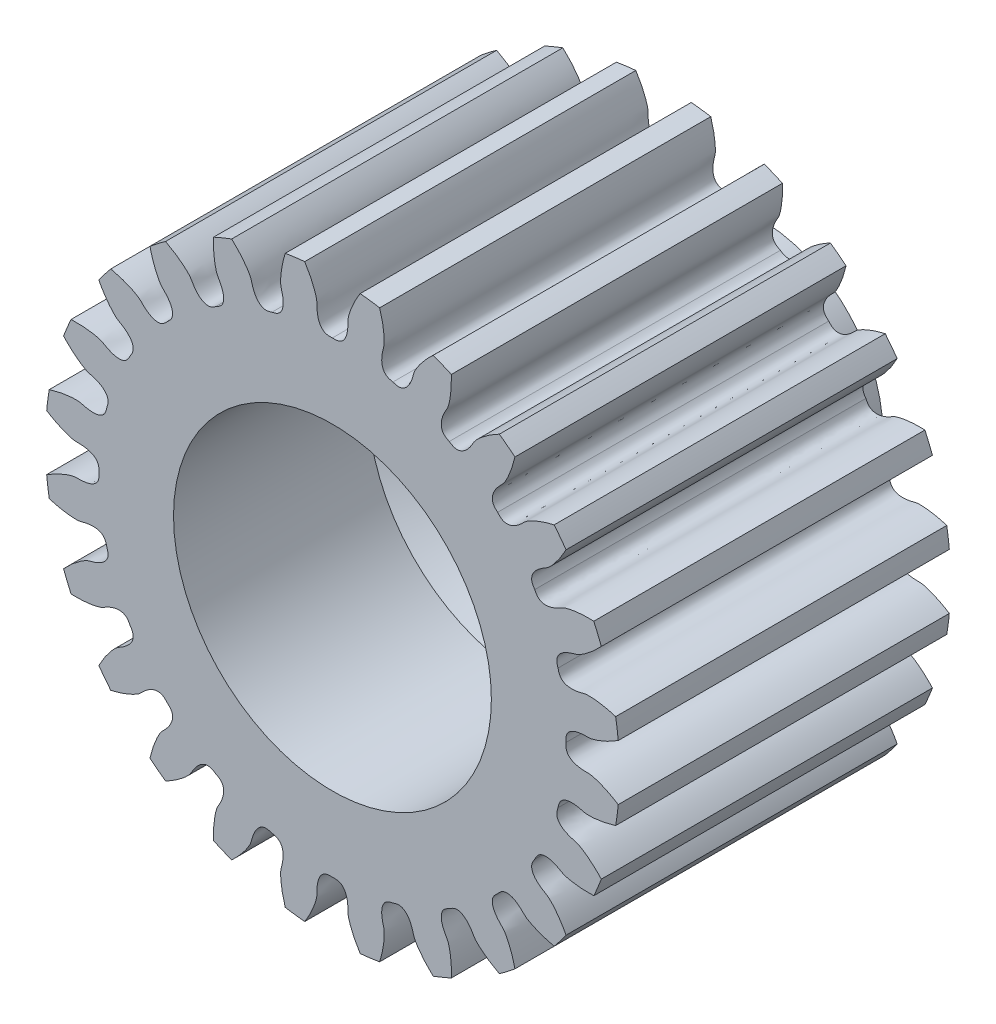
from build123d import *

# Parameters (mm, degrees)
GEAR_BASESKETCH_R                            = 2.948214286
F_112_0_DIAMETRAL_PITCH_5_4429MM_P_D_DEPTH   = 1.7
TOOTH_CUT_FINE_PITCH_INVOLUTE_14_5_DEG_DEPTH = 5.502658653
TOOTH_PATTERN_24_24_COUNT                    = 24
TALADRO_DE_MARGEN_PARA_42_D                  = 3.2639
TALADRO_DE_MARGEN_PARA_42_DEPTH              = 2
TALADRO_DE_MARGEN_PARA_42_TIP                = 0.980574487
CROQUIS6_R                                   = 1.25
SALIENTE_EXTRUIR2_DEPTH                      = 1


with BuildPart() as part:
    # Gear-BaseSketch → 112.0 Diametral Pitch_ 5_4429mm P.D (new, symmetric)
    with BuildSketch(Plane.XY):
        Circle(GEAR_BASESKETCH_R)
    extrude(amount=F_112_0_DIAMETRAL_PITCH_5_4429MM_P_D_DEPTH, both=True)

    # Tooth-Sketch_ Backlash_ 0_0000mm → Tooth-Cut_ Fine Pitch Involute 14.5 deg (cut, symmetric)
    with BuildSketch(Plane.XY):
        with BuildLine():
            ThreePointArc((-0.344773621, 3.022354987), (0, 3.041956364), (0.344773621, 3.022354987))
            add(Edge.make_bspline(
                [(0.344773621, 3.022354987), (0.323132077, 2.993097244), (0.293326137, 2.949655203), (0.258479156, 2.891726791), (0.236852665, 2.852434168), (0.218497753, 2.815826883), (0.20317534, 2.782093144), (0.190628588, 2.751407237), (0.180617716, 2.723925996), (0.172816213, 2.699797925), (0.167125534, 2.679134237), (0.156910837, 2.639187192), (0.160144106, 2.601861708), (0.157865833, 2.568465201), (0.156984242, 2.557996423), (0.155008568, 2.540585165), (0.150898063, 2.516967422), (0.143655388, 2.490460863), (0.133874394, 2.466028576), (0.120714317, 2.443271447), (0.102482266, 2.422302042), (0.064546349, 2.396057984), (0.025074879, 2.396694296), (0, 2.398201176)],
                knots=[0, 0, 0, 0, 0.142360689, 0.205914568, 0.264384138, 0.317769397, 0.366070347, 0.409286986, 0.447419316, 0.480467336, 0.508431047, 0.531310449, 0.641348821, 0.651929381, 0.662301592, 0.682440305, 0.720465671, 0.755956318, 0.789741861, 0.823160023, 0.85829397, 0.897790932, 1, 1, 1, 1], degree=3))
            add(Edge.make_bspline(
                [(-0.344773621, 3.022354987), (-0.323132077, 2.993097244), (-0.293326137, 2.949655203), (-0.258479156, 2.891726791), (-0.236852665, 2.852434168), (-0.218497753, 2.815826883), (-0.20317534, 2.782093144), (-0.190628588, 2.751407237), (-0.180617716, 2.723925996), (-0.172816213, 2.699797925), (-0.167125534, 2.679134237), (-0.156910837, 2.639187192), (-0.160144106, 2.601861708), (-0.157865833, 2.568465201), (-0.156984242, 2.557996423), (-0.155008568, 2.540585165), (-0.150898063, 2.516967422), (-0.143655388, 2.490460863), (-0.133874394, 2.466028576), (-0.120714317, 2.443271447), (-0.102482266, 2.422302042), (-0.064546349, 2.396057984), (-0.025074879, 2.396694296), (0, 2.398201176)],
                knots=[0, 0, 0, 0, 0.142360689, 0.205914568, 0.264384138, 0.317769397, 0.366070347, 0.409286986, 0.447419316, 0.480467336, 0.508431047, 0.531310449, 0.641348821, 0.651929381, 0.662301592, 0.682440305, 0.720465671, 0.755956318, 0.789741861, 0.823160023, 0.85829397, 0.897790932, 1, 1, 1, 1], degree=3))
        make_face()
    tooth_cut_fine_pitch_involute_14_5_deg = extrude(amount=TOOTH_CUT_FINE_PITCH_INVOLUTE_14_5_DEG_DEPTH, both=True, mode=Mode.SUBTRACT)

    # Tooth Pattern_ 24 _ 24: Tooth-Cut_ Fine Pitch Involute 14.5 deg ×24 about axis
    tooth_pattern_24_24_axis = Axis((0, 0, -88.99), (0, 0, 1))
    for i in range(1, TOOTH_PATTERN_24_24_COUNT):
        add(tooth_cut_fine_pitch_involute_14_5_deg.rotate(tooth_pattern_24_24_axis, i * 360 / TOOTH_PATTERN_24_24_COUNT), mode=Mode.SUBTRACT)

    # Taladro de margen para _42
    with Locations(Plane.XY.offset(1.7)):
        with Locations((0, 0)):
            Hole(TALADRO_DE_MARGEN_PARA_42_D / 2, depth=TALADRO_DE_MARGEN_PARA_42_DEPTH)
            with Locations((0, 0, -(TALADRO_DE_MARGEN_PARA_42_DEPTH + TALADRO_DE_MARGEN_PARA_42_TIP / 2))):  # 118° drill point
                Cone(0, TALADRO_DE_MARGEN_PARA_42_D / 2, TALADRO_DE_MARGEN_PARA_42_TIP, mode=Mode.SUBTRACT)

    # Croquis6 → Saliente-Extruir2 (add)
    with BuildSketch(Plane(origin=(0, 0, -1.7), x_dir=(-1, 0, 0), z_dir=(0, 0, -1))):
        Circle(CROQUIS6_R)
    extrude(amount=SALIENTE_EXTRUIR2_DEPTH)


solid = part.part
